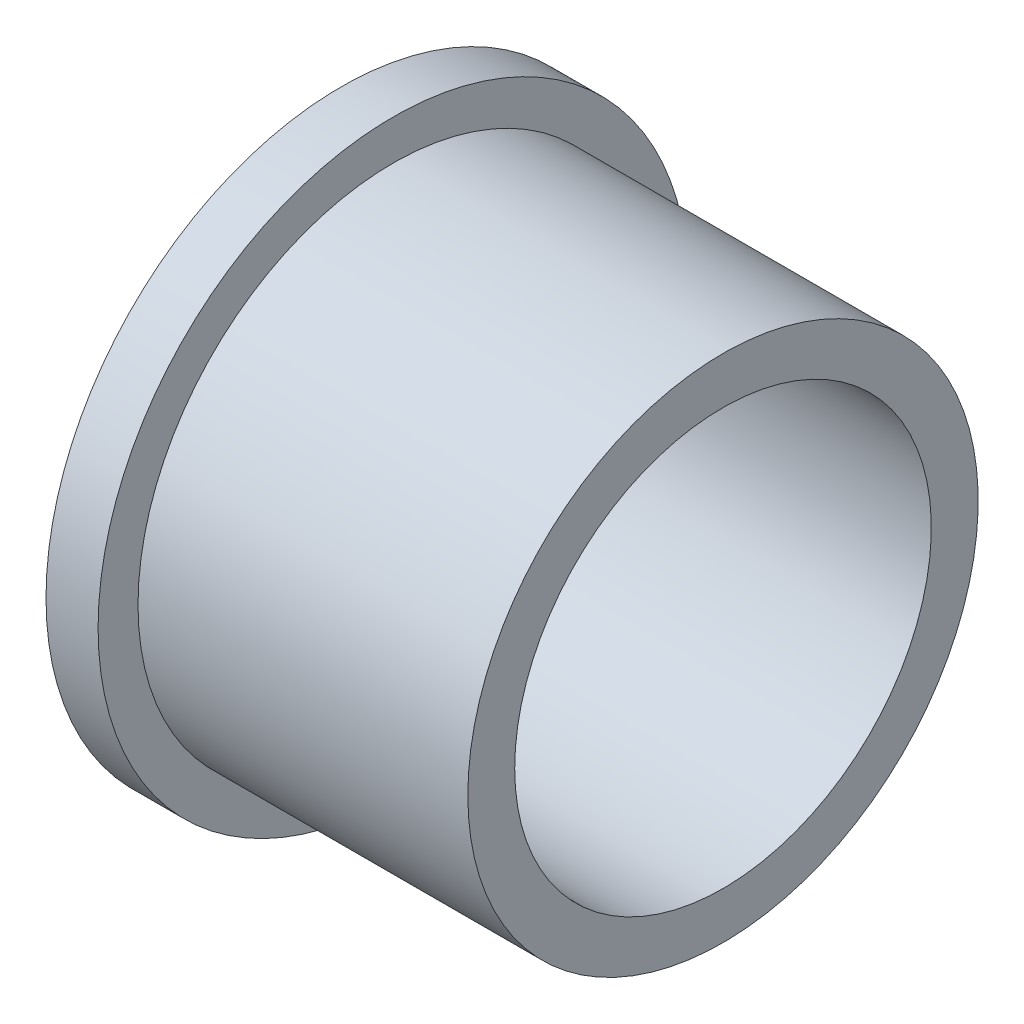
from build123d import *


with BuildPart() as part:
    # Sketch1 → Revolve1 (revolve)
    with BuildSketch(Plane.XY, mode=Mode.PRIVATE) as revolve1_sk:
        Polygon((-1.5, 6), (9.5, 6), (9.5, 7.35), (0, 7.35), (0, 8.5), (-1.5, 8.5), align=None)
    revolve(revolve1_sk.sketch.rotate(Axis((0, 0, 0), (1, 0, 0)), 90), axis=Axis((0, 0, 0), (1, 0, 0)))  # turned: the seam where the file's is


solid = part.part
